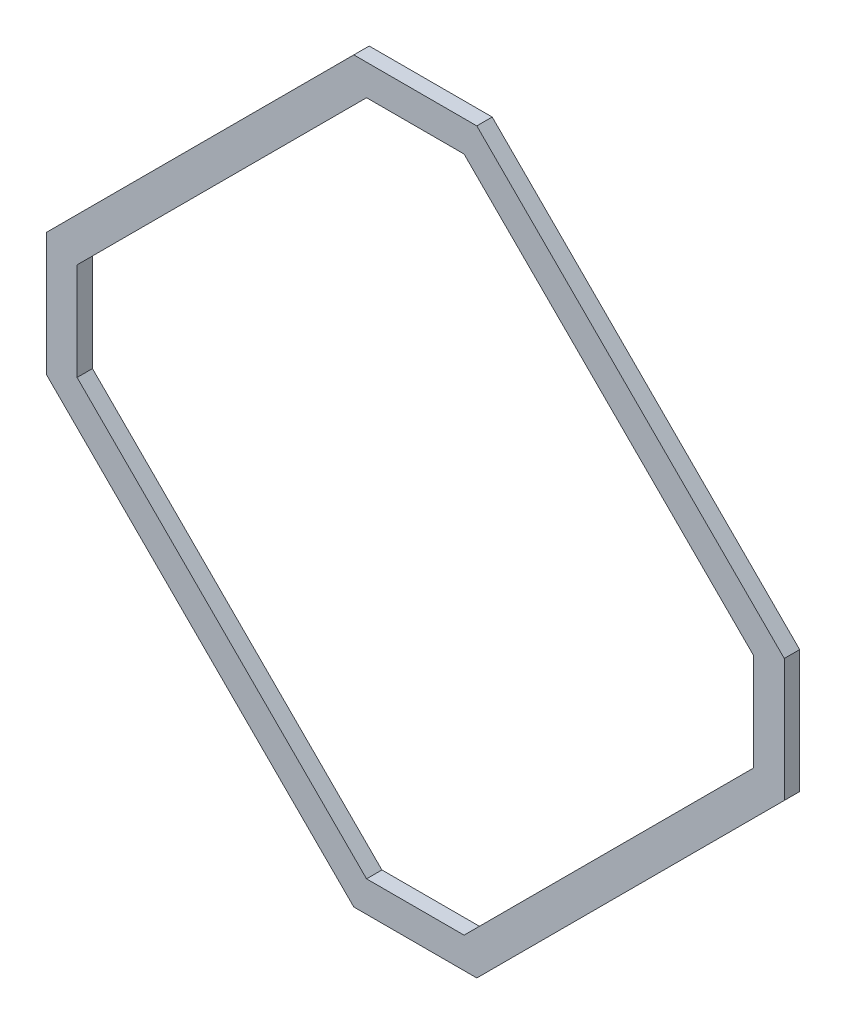
from build123d import *

# Parameters (mm, degrees)
BOSS_EXTRUDE1_DEPTH = 3.175


with BuildPart() as part:
    # Sketch1 → Boss-Extrude1 (new body)
    with BuildSketch(Plane.XY):
        Polygon((63.5, -78.5114), (0, -15.0114), (-25.4, -15.0114), (-88.9, -78.5114), (-88.9, -103.9114), (-25.4, -167.4114), (0, -167.4114), (63.5, -103.9114), align=None)
        Polygon((57.15, -81.141656121), (-2.630256121, -21.3614), (-22.769743879, -21.3614), (-82.55, -81.141656121), (-82.55, -101.281143879), (-22.769743879, -161.0614), (-2.630256121, -161.0614), (57.15, -101.281143879), align=None, mode=Mode.SUBTRACT)
    extrude(amount=BOSS_EXTRUDE1_DEPTH)


solid = part.part
